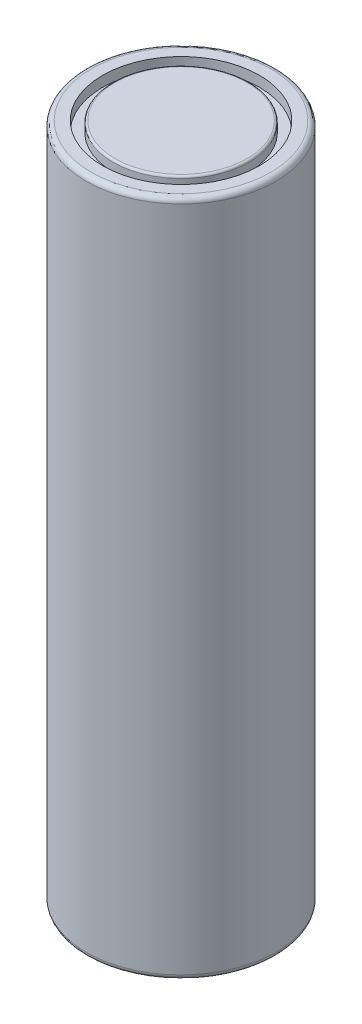
from build123d import *

# Parameters (mm, degrees)
SKETCH1_R           = 9.1
BOSS_EXTRUDE1_DEPTH = 65
SKETCH2_R           = 7.515816548
SKETCH2_R_2         = 6.528062022
CUT_EXTRUDE1_DEPTH  = 1
FILLET1_R           = 0.5
SKETCH3_R           = 7.515816548
SKETCH3_R_2         = 6.528062022
CUT_EXTRUDE2_DEPTH  = 1
FILLET2_R           = 0.2


with BuildPart() as part:
    # Sketch1 → Boss-Extrude1 (new body)
    with BuildSketch(Plane(origin=(0, 0, 0), x_dir=(1, 0, 0), z_dir=(0, 1, 0))):
        Circle(SKETCH1_R)
    extrude(amount=BOSS_EXTRUDE1_DEPTH)

    # Sketch2 → Cut-Extrude1 (cut)
    with BuildSketch(Plane(origin=(0, 65, 0), x_dir=(1, 0, 0), z_dir=(0, 1, 0))):
        Circle(SKETCH2_R)
        Circle(SKETCH2_R_2, mode=Mode.SUBTRACT)
    extrude(amount=-CUT_EXTRUDE1_DEPTH, mode=Mode.SUBTRACT)

    # Fillet1
    fillet1_edges = [part.edges().sort_by_distance(p)[0] for p in [
        (-9.1, 0, 0),
        (-9.1, 65, 0),
    ]]
    fillet(fillet1_edges, radius=FILLET1_R)

    # Sketch3 → Cut-Extrude2 (cut)
    with BuildSketch(Plane.XZ):
        Circle(SKETCH3_R)
        Circle(SKETCH3_R_2, mode=Mode.SUBTRACT)
    extrude(amount=-CUT_EXTRUDE2_DEPTH, mode=Mode.SUBTRACT)

    # Fillet2
    fillet2_edges = [part.edges().sort_by_distance(p)[0] for p in [
        (-6.528062022, 0, 0),
        (-6.528062022, 65, 0),
    ]]
    fillet(fillet2_edges, radius=FILLET2_R)


solid = part.part
